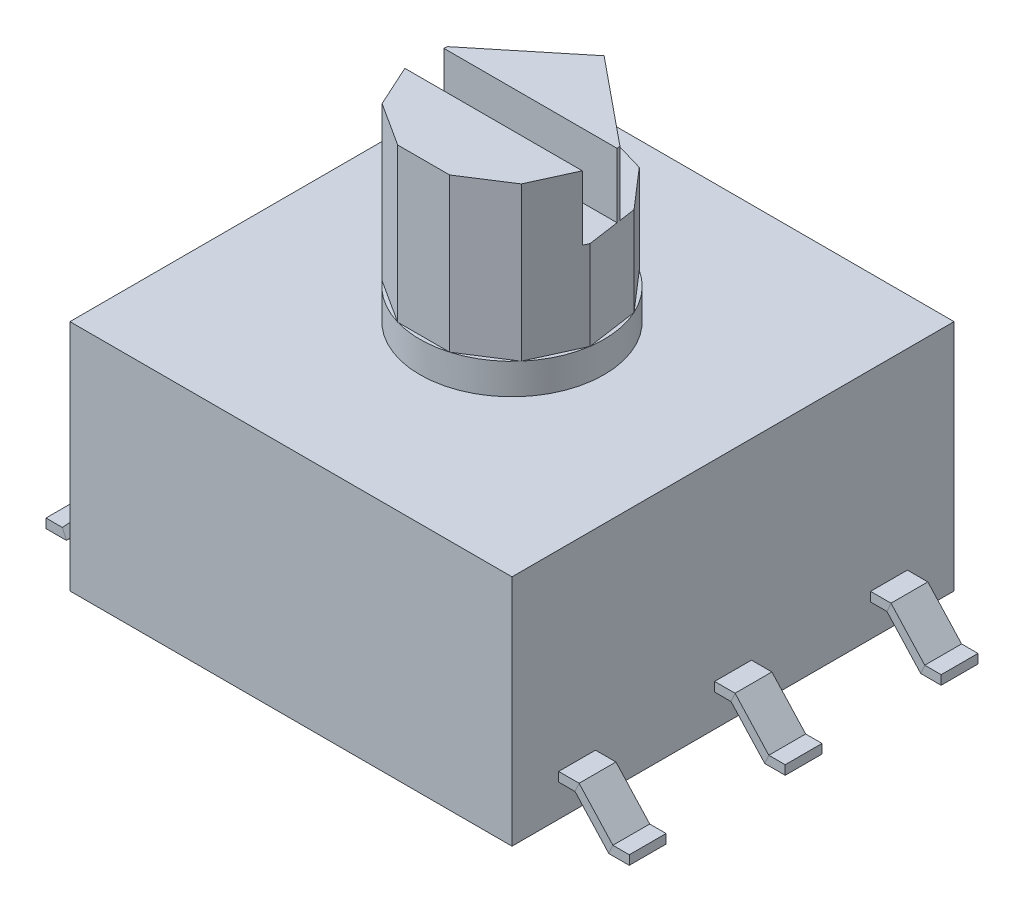
from build123d import *

# Parameters (mm, degrees)
SKETCH1_W               = 7.2
SKETCH1_H               = 7.2
BOSS_EXTRUDE1_DEPTH     = 3.8
SKETCH2_R               = 1.5
BOSS_EXTRUDE2_DEPTH     = 3
SKETCH3_R               = 1.65
CUT_EXTRUDE1_DEPTH      = 2.5
CUT_EXTRUDE2_DEPTH      = 1.05
SKETCH6_W               = 0.6
SKETCH6_H               = 0.15
LPATTERN1_COUNT         = 2
LPATTERN1_PITCH         = 2.54
LPATTERN1_COL_COUNT     = 2
LPATTERN1_COL_PITCH     = 2.54
MIRROR1_COPY_1_SKETCH_W = 0.6
MIRROR1_COPY_1_SKETCH_H = 0.15
MIRROR1_COPY_2_SKETCH_W = 0.6
MIRROR1_COPY_2_SKETCH_H = 0.15


with BuildPart() as part:
    # Sketch1 → Boss-Extrude1 (new body)
    with BuildSketch(Plane(origin=(0, 0, 0), x_dir=(1, 0, 0), z_dir=(0, 1, 0))):
        Rectangle(SKETCH1_W, SKETCH1_H)
    extrude(amount=BOSS_EXTRUDE1_DEPTH)

    # Sketch2 → Boss-Extrude2 (add)
    with BuildSketch(Plane(origin=(0, 3.8, 0), x_dir=(1, 0, 0), z_dir=(0, 1, 0))):
        Circle(SKETCH2_R)
    extrude(amount=BOSS_EXTRUDE2_DEPTH)

    # Sketch3 → Cut-Extrude1 (cut)
    with BuildSketch(Plane(origin=(0, 6.8, 0), x_dir=(1, 0, 0), z_dir=(0, 1, 0))):
        Circle(SKETCH3_R)
        Polygon((0, 1.5), (-0.810961226, 1.261880299), (-1.364447993, 0.62312252), (-1.484732163, -0.213472257), (-1.133624362, -0.982291101), (-0.422598835, -1.43923946), (0.422598835, -1.43923946), (1.133624362, -0.982291101), (1.484732163, -0.213472257), (1.364447993, 0.62312252), (0.810961226, 1.261880299), align=None, mode=Mode.SUBTRACT)
    extrude(amount=-CUT_EXTRUDE1_DEPTH, mode=Mode.SUBTRACT)

    # Sketch4 → Cut-Extrude2 (cut)
    with BuildSketch(Plane(origin=(0, 6.8, 0), x_dir=(1, 0, 0), z_dir=(0, 1, 0))):
        Polygon((1.410905998, 0.3), (-1.410905998, 0.3), (-1.484732163, -0.213472257), (-1.445216267, -0.3), (1.445216267, -0.3), (1.484732163, -0.213472257), align=None)
        Polygon((-1.364447993, 0.62312252), (-1.403086684, 0.35438452), (0, 1.5), (-0.810961226, 1.261880299), align=None)
        Polygon((0.810961226, 1.261880299), (0, 1.5), (1.403086684, 0.35438452), (1.364447993, 0.62312252), align=None)
    extrude(amount=-CUT_EXTRUDE2_DEPTH, mode=Mode.SUBTRACT)

    # Sweep1: sweep along a path in Sketch5
    with BuildLine(Plane.XY) as sweep1_path:
        Line((3.6, 0.6), (3.9, 0.6))
        Line((3.9, 0.6), (4.45, 0))
        Line((4.45, 0), (4.75, 0))
    # Sketch6 → Sweep1 (sweep)
    with BuildSketch(Plane(origin=(3.6, 0, 0), x_dir=(0, 0, -1), z_dir=(1, 0, 0))):
        with Locations((0, 0.6)):
            Rectangle(SKETCH6_W, SKETCH6_H)
    sweep1 = sweep(path=sweep1_path.line, transition=Transition.RIGHT)

    # LPattern1: Sweep1 ×2
    with Locations(*[(0, 0, -i * LPATTERN1_PITCH) for i in range(1, LPATTERN1_COUNT)]):
        add(sweep1)

    # LPattern1 col: Sweep1 ×2
    with Locations(*[(0, 0, i * LPATTERN1_COL_PITCH) for i in range(1, LPATTERN1_COL_COUNT)]):
        add(sweep1)

    # Mirror1: Sweep1 across plane
    add(sweep1.mirror(Plane(origin=(0, 0, 0), x_dir=(0, 0, 1), z_dir=(1, 0, 0))))

    # Mirror1 copy 1: sweep along a path in Mirror1 copy 1 path
    with BuildLine(Plane(origin=(0, 0, -2.54), x_dir=(-1, 0, 0), z_dir=(0, 0, 1))) as mirror1_copy_1_path:
        Line((3.6, -0.6), (3.9, -0.6))
        Line((3.9, -0.6), (4.45, 0))
        Line((4.45, 0), (4.75, 0))
    # Mirror1 copy 1 sketch → Mirror1 copy 1 (sweep)
    with BuildSketch(Plane(origin=(-3.6, 0, -2.54), x_dir=(0, 0, -1), z_dir=(-1, 0, 0))):
        with Locations((0, -0.6)):
            Rectangle(MIRROR1_COPY_1_SKETCH_W, MIRROR1_COPY_1_SKETCH_H)
    sweep(path=mirror1_copy_1_path.line, transition=Transition.RIGHT)

    # Mirror1 copy 2: sweep along a path in Mirror1 copy 2 path
    with BuildLine(Plane(origin=(0, 0, 2.54), x_dir=(-1, 0, 0), z_dir=(0, 0, 1))) as mirror1_copy_2_path:
        Line((3.6, -0.6), (3.9, -0.6))
        Line((3.9, -0.6), (4.45, 0))
        Line((4.45, 0), (4.75, 0))
    # Mirror1 copy 2 sketch → Mirror1 copy 2 (sweep)
    with BuildSketch(Plane(origin=(-3.6, 0, 2.54), x_dir=(0, 0, -1), z_dir=(-1, 0, 0))):
        with Locations((0, -0.6)):
            Rectangle(MIRROR1_COPY_2_SKETCH_W, MIRROR1_COPY_2_SKETCH_H)
    sweep(path=mirror1_copy_2_path.line, transition=Transition.RIGHT)


solid = part.part
